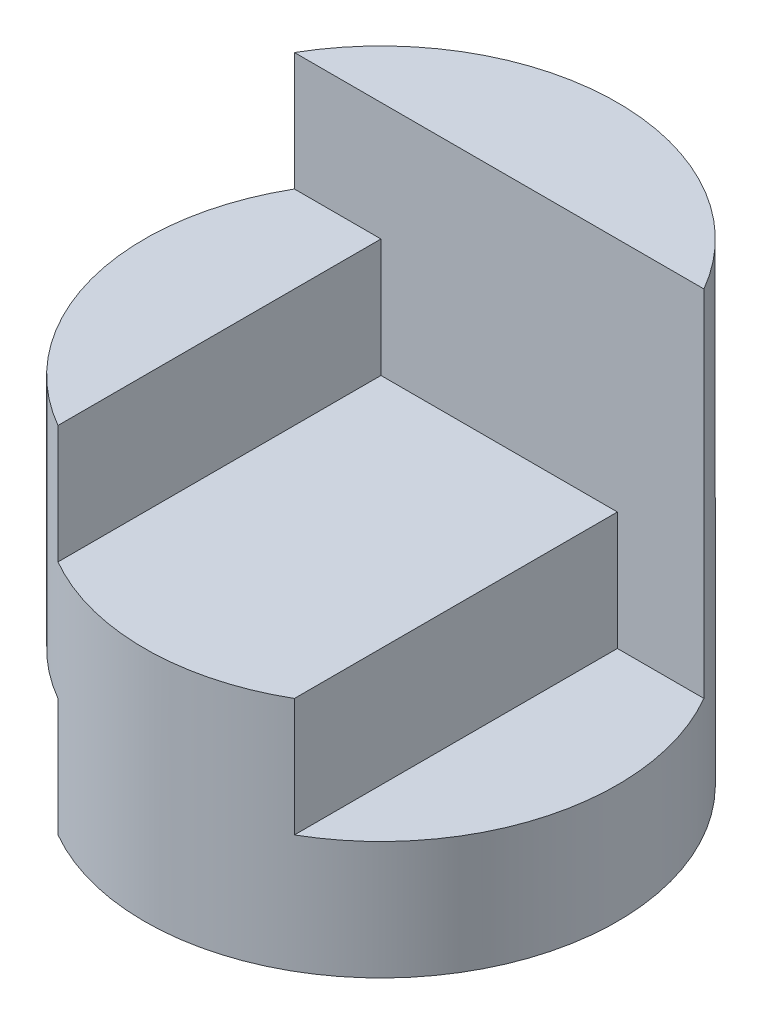
from build123d import *

# Parameters (mm, degrees)
SKETCH1_R               = 2
BOSS_EXTRUDE1_DEPTH     = 4
SKETCH2_W               = 1
SKETCH2_H               = 1
CUT_EXTRUDE1_DEPTH      = 3
CUT_EXTRUDE1_DEPTH_BACK = 1


with BuildPart() as part:
    # Sketch1 → Boss-Extrude1 (new body)
    with BuildSketch(Plane(origin=(0, 0, 0), x_dir=(1, 0, 0), z_dir=(0, 1, 0))):
        Circle(SKETCH1_R)
    extrude(amount=BOSS_EXTRUDE1_DEPTH)

    # Sketch2 → Cut-Extrude1 (cut, two sides)
    with BuildSketch(Plane.XY) as cut_extrude1_sk:
        Polygon((-2, 4), (2, 4), (2, 1), (1, 1), (1, 2), (-1, 2), (-1, 3), (-2, 3), align=None)
        with Locations((-1.5, 0.5)):
            Rectangle(SKETCH2_W, SKETCH2_H)
    extrude(amount=CUT_EXTRUDE1_DEPTH, mode=Mode.SUBTRACT)
    extrude(cut_extrude1_sk.sketch, amount=-CUT_EXTRUDE1_DEPTH_BACK, mode=Mode.SUBTRACT)


solid = part.part
